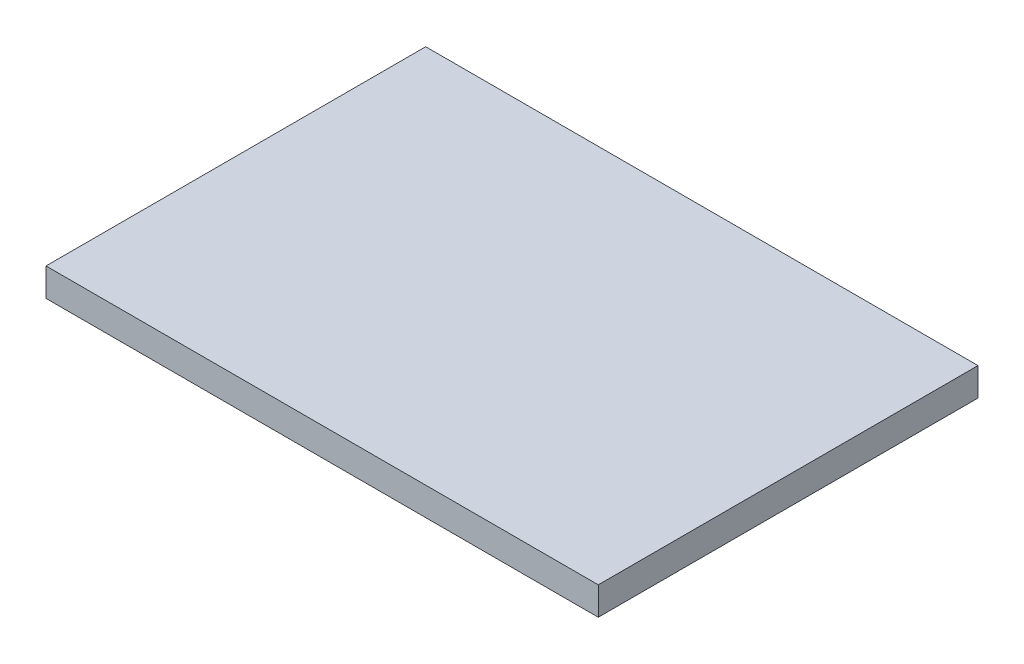
from build123d import *

# Parameters (mm, degrees)
SKETCH1_W           = 39.269908169
SKETCH1_H           = 27
BOSS_EXTRUDE1_DEPTH = 2


with BuildPart() as part:
    # Sketch1 → Boss-Extrude1 (new body)
    with BuildSketch(Plane(origin=(0, 0, 0), x_dir=(1, 0, 0), z_dir=(0, 1, 0))):
        with Locations((-1.847805491, 13.5)):
            Rectangle(SKETCH1_W, SKETCH1_H)
    extrude(amount=BOSS_EXTRUDE1_DEPTH)


solid = part.part
